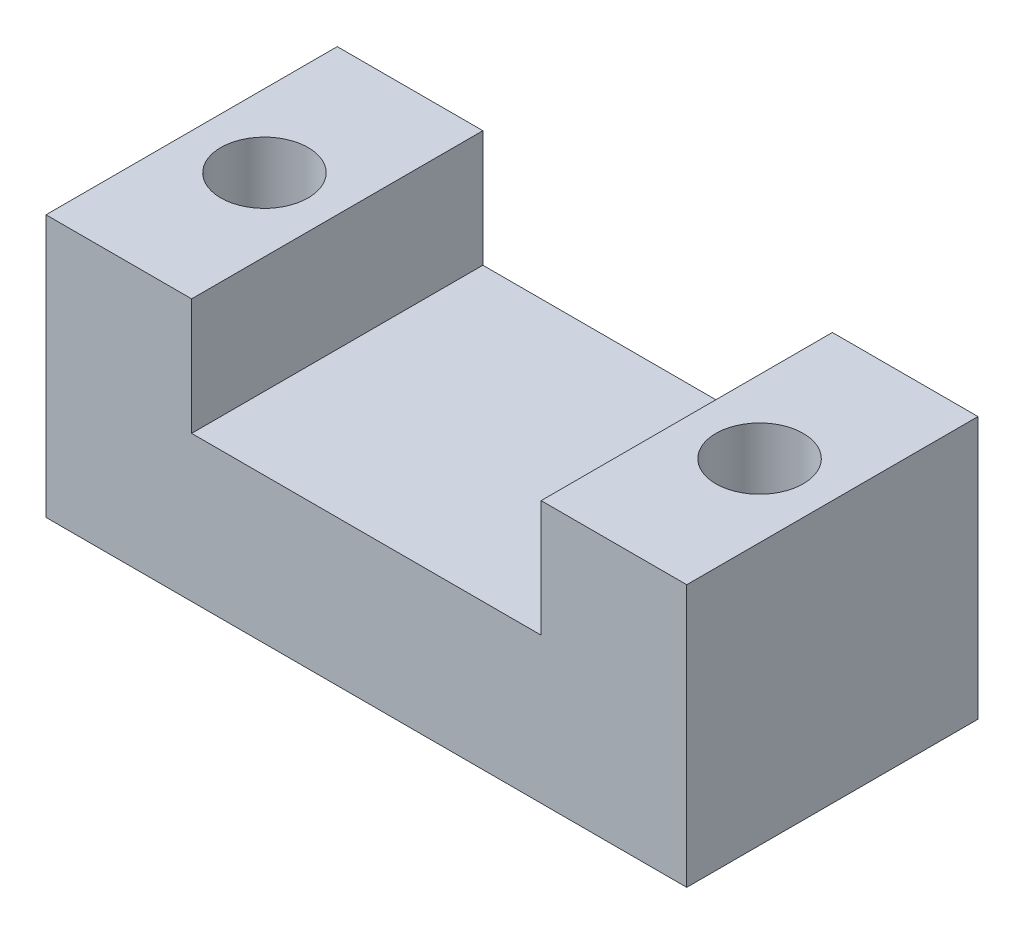
from build123d import *

# Parameters (mm, degrees)
SKETCH_1_W      = 22
SKETCH_1_H      = 10
SKETCH_1_R      = 1.5
EXTRUDE_1_DEPTH = 5
SKETCH_2_W      = 5
SKETCH_2_H      = 10
SKETCH_2_R      = 1.5
EXTRUDE_2_DEPTH = 4


with BuildPart() as part:
    # 草圖1 → 填料-伸長1 (new body)
    with BuildSketch(Plane(origin=(0, 0, 0), x_dir=(1, 0, 0), z_dir=(0, 1, 0))):
        Rectangle(SKETCH_1_W, SKETCH_1_H)
        with Locations((-8.5, 0)):
            Circle(SKETCH_1_R, mode=Mode.SUBTRACT)
        with Locations((8.5, 0)):
            Circle(SKETCH_1_R, mode=Mode.SUBTRACT)
    extrude(amount=EXTRUDE_1_DEPTH)

    # 草圖2 → 填料-伸長2 (add)
    with BuildSketch(Plane(origin=(0, 5, 0), x_dir=(1, 0, 0), z_dir=(0, 1, 0))):
        with Locations((-8.5, 0)):
            Rectangle(SKETCH_2_W, SKETCH_2_H)
        with Locations((-8.5, 0)):
            Circle(SKETCH_2_R, mode=Mode.SUBTRACT)
        with Locations((8.5, 0)):
            Rectangle(SKETCH_2_W, SKETCH_2_H)
        with Locations((8.5, 0)):
            Circle(SKETCH_2_R, mode=Mode.SUBTRACT)
    extrude(amount=EXTRUDE_2_DEPTH)


solid = part.part
